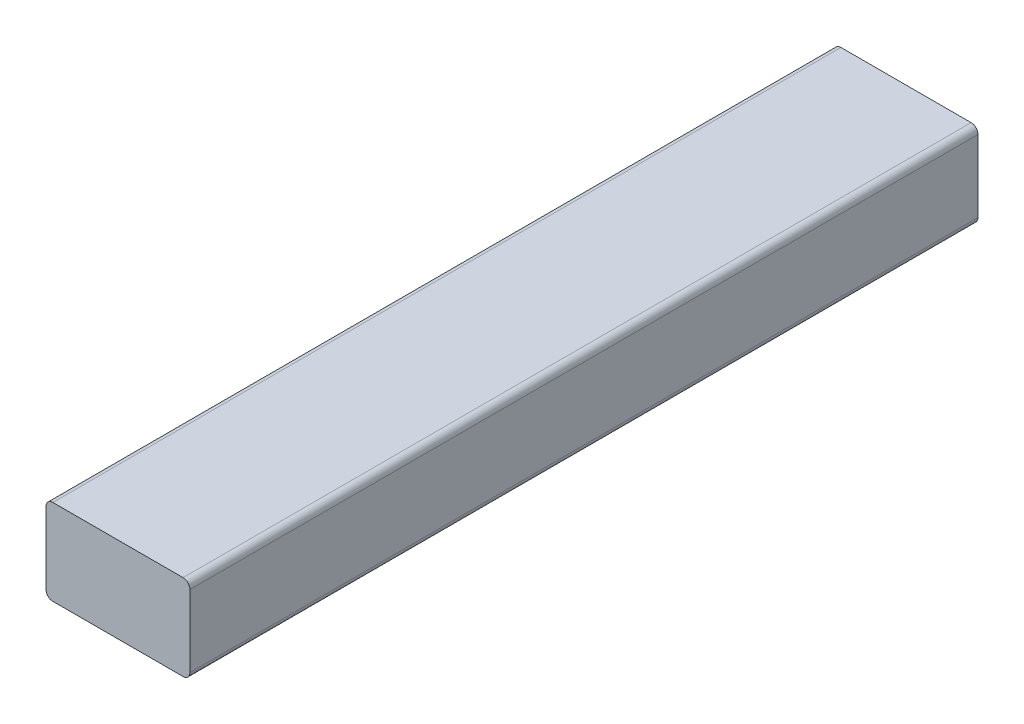
from build123d import *

# Parameters (mm, degrees)
SKETCH1_W           = 42
SKETCH1_H           = 25
BOSS_EXTRUDE1_DEPTH = 230
FILLET1_R           = 2


with BuildPart() as part:
    # Sketch1 → Boss-Extrude1 (new body)
    with BuildSketch(Plane.XY):
        with Locations((-8.340277778, 3.385416667)):
            Rectangle(SKETCH1_W, SKETCH1_H)
    extrude(amount=-BOSS_EXTRUDE1_DEPTH)

    # Fillet1
    fillet1_edges = [part.edges().sort_by_distance(p)[0] for p in [
        (-29.340277778, 15.885416667, -115),
        (12.659722222, 15.885416667, -115),
        (12.659722222, -9.114583333, -115),
        (-29.340277778, -9.114583333, -115),
    ]]
    fillet(fillet1_edges, radius=FILLET1_R)


solid = part.part
